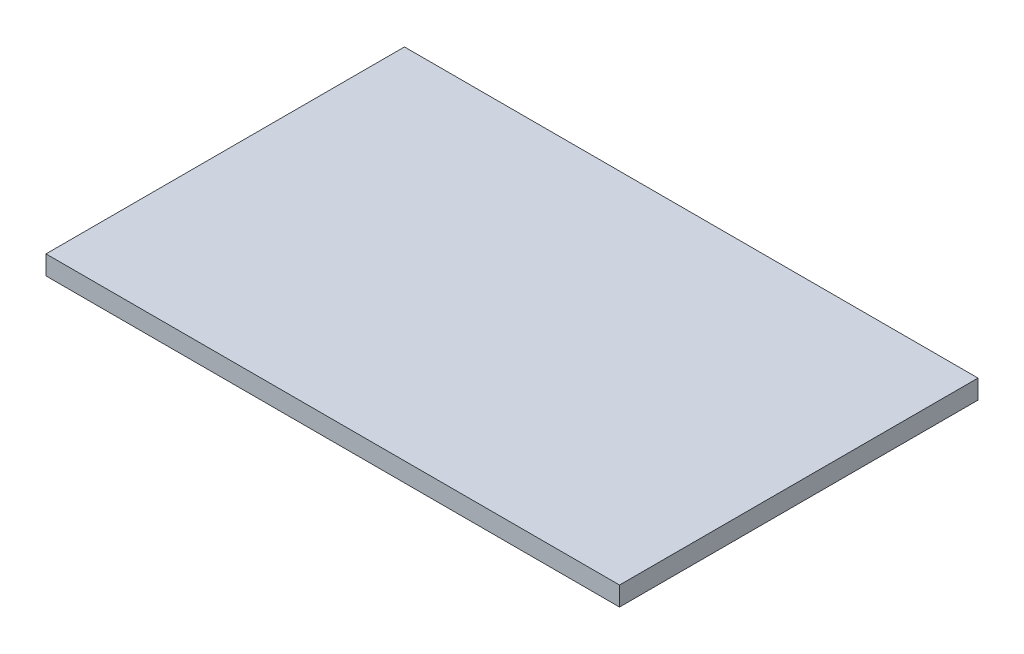
from build123d import *

# Parameters (mm, degrees)
SKETCH1_W           = 48
SKETCH1_H           = 30
BOSS_EXTRUDE1_DEPTH = 1.6


with BuildPart() as part:
    # Sketch1 → Boss-Extrude1 (new body)
    with BuildSketch(Plane(origin=(0, 0, 0), x_dir=(1, 0, 0), z_dir=(0, 1, 0))):
        with Locations((24, 15)):
            Rectangle(SKETCH1_W, SKETCH1_H)
    extrude(amount=BOSS_EXTRUDE1_DEPTH)


solid = part.part
